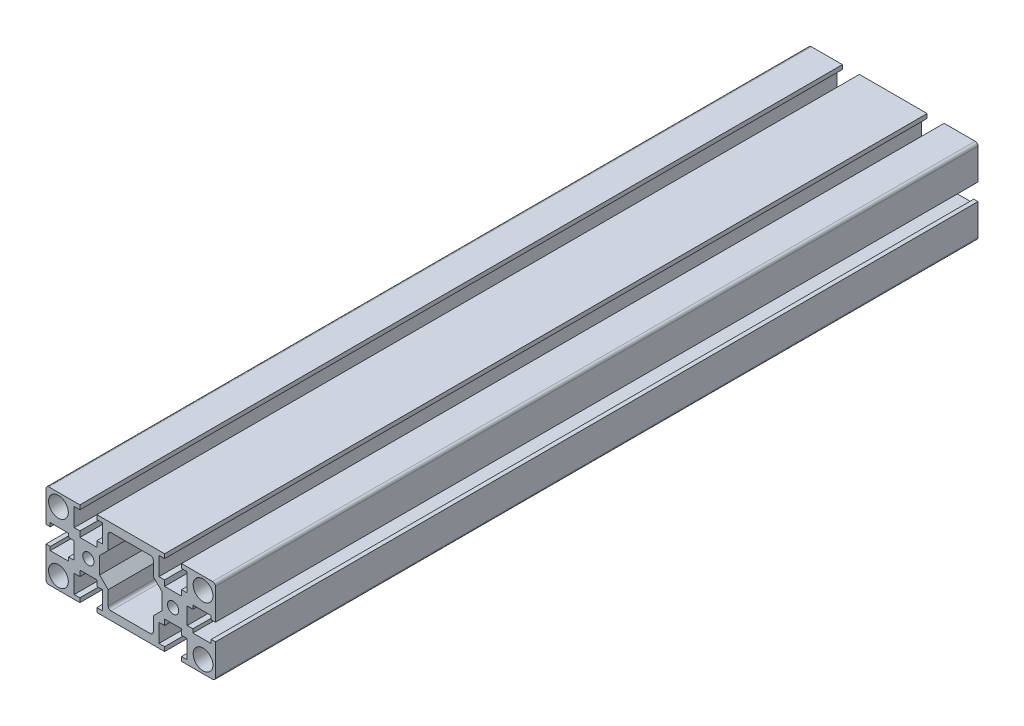
from build123d import *

# Parameters (mm, degrees)
SKETCH1_R           = 2
SKETCH1_R_2         = 3.5
BOSS_EXTRUDE1_DEPTH = 270


with BuildPart() as part:
    # Sketch1 → Boss-Extrude1 (new body)
    with BuildSketch(Plane.XY):
        with BuildLine():
            Line((-5, -3), (-5, 3))
            Line((-5, 3), (-7, 3))
            Line((-7, 3), (-7, 4.298364791))
            Line((-7, 4.298364791), (-13.5, 4.298364791))
            Line((-13.5, 4.298364791), (-13.5, 3))
            Line((-13.5, 3), (-15, 3))
            Line((-15, 3), (-15, 14))
            ThreePointArc((-15, 14), (-14.707106781, 14.707106781), (-14, 15))
            Line((-14, 15), (-3, 15))
            Line((-3, 15), (-3, 13.5))
            Line((-3, 13.5), (-5, 13.5))
            Line((-5, 13.5), (-5, 7))
            Line((-5, 7), (-3, 7))
            Line((-3, 7), (-3, 5))
            Line((-3, 5), (3, 5))
            Line((3, 5), (3, 7))
            Line((3, 7), (5, 7))
            Line((5, 7), (5, 13.5))
            Line((5, 13.5), (3, 13.5))
            Line((3, 13.5), (3, 15))
            Line((3, 15), (27, 15))
            Line((27, 15), (27, 13.5))
            Line((27, 13.5), (25, 13.5))
            Line((25, 13.5), (25, 7))
            Line((25, 7), (27, 7))
            Line((27, 7), (27, 5))
            Line((27, 5), (33, 5))
            Line((33, 5), (33, 7))
            Line((33, 7), (35, 7))
            Line((35, 7), (35, 13.5))
            Line((35, 13.5), (33, 13.5))
            Line((33, 13.5), (33, 15))
            Line((33, 15), (44, 15))
            ThreePointArc((44, 15), (44.707106781, 14.707106781), (45, 14))
            Line((45, 14), (45, 3))
            Line((45, 3), (43.5, 3))
            Line((43.5, 3), (43.5, 4.298364791))
            Line((43.5, 4.298364791), (37, 4.298364791))
            Line((37, 4.298364791), (37, 3))
            Line((37, 3), (35, 3))
            Line((35, 3), (35, -3))
            Line((35, -3), (37, -3))
            Line((37, -3), (37, -4.298364791))
            Line((37, -4.298364791), (43.5, -4.298364791))
            Line((43.5, -4.298364791), (43.5, -3))
            Line((43.5, -3), (45, -3))
            Line((45, -3), (45, -14))
            ThreePointArc((45, -14), (44.707106781, -14.707106781), (44, -15))
            Line((44, -15), (33, -15))
            Line((33, -15), (33, -13.5))
            Line((33, -13.5), (35, -13.5))
            Line((35, -13.5), (35, -7))
            Line((35, -7), (33, -7))
            Line((33, -7), (33, -5))
            Line((33, -5), (27, -5))
            Line((27, -5), (27, -7))
            Line((27, -7), (25, -7))
            Line((25, -7), (25, -13.5))
            Line((25, -13.5), (27, -13.5))
            Line((27, -13.5), (27, -15))
            Line((27, -15), (3, -15))
            Line((3, -15), (3, -13.5))
            Line((3, -13.5), (5, -13.5))
            Line((5, -13.5), (5, -7))
            Line((5, -7), (3, -7))
            Line((3, -7), (3, -5))
            Line((3, -5), (-3, -5))
            Line((-3, -5), (-3, -7))
            Line((-3, -7), (-5, -7))
            Line((-5, -7), (-5, -13.5))
            Line((-5, -13.5), (-3, -13.5))
            Line((-3, -13.5), (-3, -15))
            Line((-3, -15), (-14, -15))
            ThreePointArc((-14, -15), (-14.707106781, -14.707106781), (-15, -14))
            Line((-15, -14), (-15, -3))
            Line((-15, -3), (-13.5, -3))
            Line((-13.5, -3), (-13.5, -4.298364791))
            Line((-13.5, -4.298364791), (-7, -4.298364791))
            Line((-7, -4.298364791), (-7, -3))
            Line((-7, -3), (-5, -3))
        make_face()
        Circle(SKETCH1_R, mode=Mode.SUBTRACT)
        with Locations((-10.606601718, 10.606601718)):
            Circle(SKETCH1_R_2, mode=Mode.SUBTRACT)
        with Locations((40.606601718, 10.606601718)):
            Circle(SKETCH1_R_2, mode=Mode.SUBTRACT)
        with Locations((30, 0)):
            Circle(SKETCH1_R, mode=Mode.SUBTRACT)
        with Locations((40.606601718, -10.606601718)):
            Circle(SKETCH1_R_2, mode=Mode.SUBTRACT)
        with Locations((-10.606601718, -10.606601718)):
            Circle(SKETCH1_R_2, mode=Mode.SUBTRACT)
        with BuildLine():
            Line((4, -3), (4, 3))
            Line((4, 3), (7, 6))
            Line((7, 6), (7, 11))
            ThreePointArc((7, 11), (7.292893219, 11.707106781), (8, 12))
            Line((8, 12), (22, 12))
            ThreePointArc((22, 12), (22.707106781, 11.707106781), (23, 11))
            Line((23, 11), (23, 6))
            Line((23, 6), (26, 3))
            Line((26, 3), (26, -3))
            Line((26, -3), (23, -6))
            Line((23, -6), (23, -11))
            ThreePointArc((23, -11), (22.707106781, -11.707106781), (22, -12))
            Line((22, -12), (8, -12))
            ThreePointArc((8, -12), (7.292893219, -11.707106781), (7, -11))
            Line((7, -11), (7, -6))
            Line((7, -6), (4, -3))
        make_face(mode=Mode.SUBTRACT)
    extrude(amount=BOSS_EXTRUDE1_DEPTH)


solid = part.part
